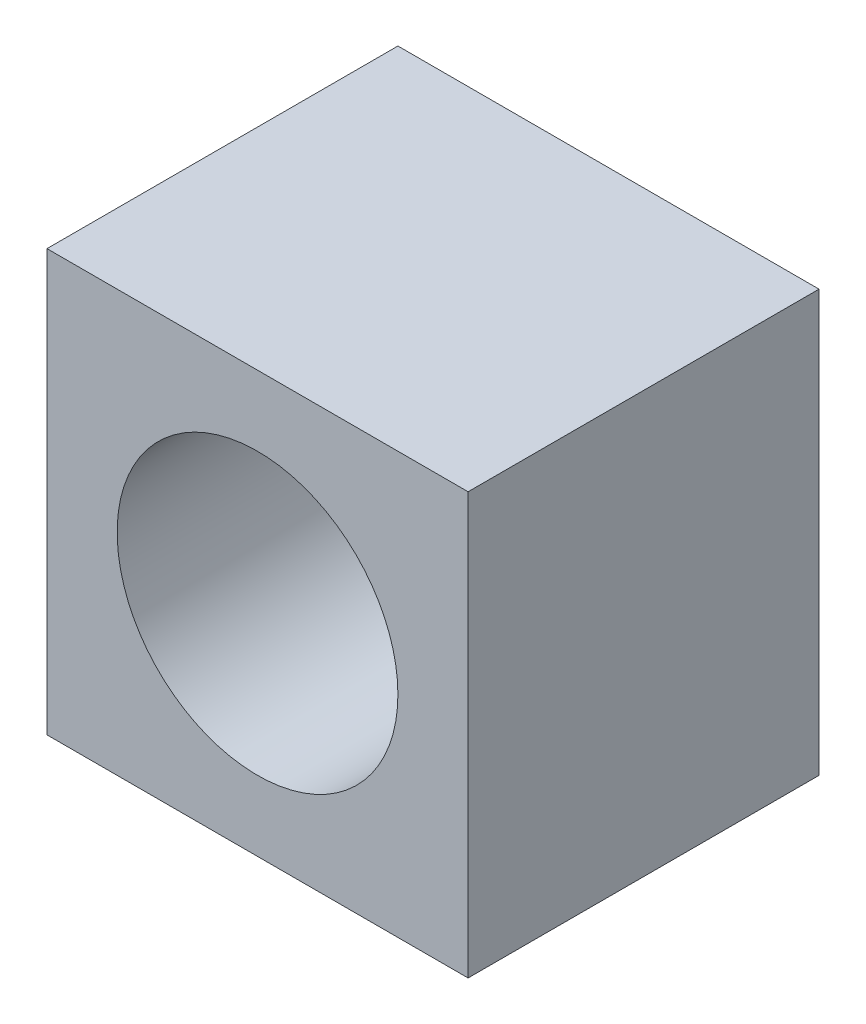
from build123d import *

# Parameters (mm, degrees)
SKETCH1_W           = 12
SKETCH1_H           = 12
BOSS_EXTRUDE2_DEPTH = 10
SKETCH2_R           = 4
CUT_EXTRUDE1_DEPTH  = 8


with BuildPart() as part:
    # Sketch1 → Boss-Extrude2 (new body)
    with BuildSketch(Plane.XY):
        Rectangle(SKETCH1_W, SKETCH1_H)
    extrude(amount=BOSS_EXTRUDE2_DEPTH)

    # Sketch2 → Cut-Extrude1 (cut)
    with BuildSketch(Plane.XY.offset(10)):
        Circle(SKETCH2_R)
    extrude(amount=-CUT_EXTRUDE1_DEPTH, mode=Mode.SUBTRACT)


solid = part.part
